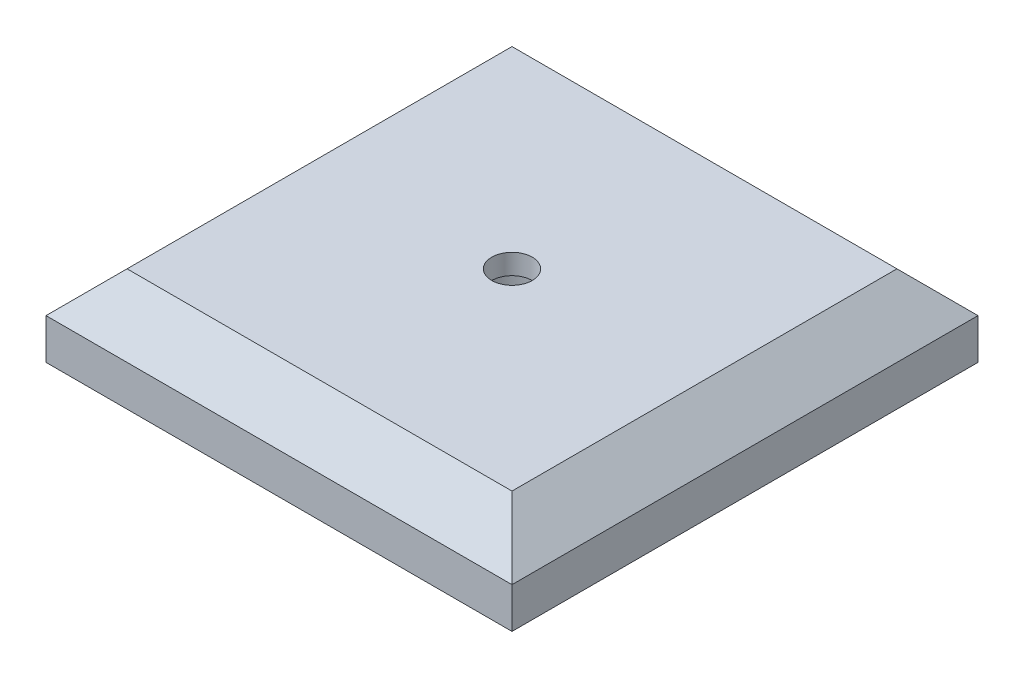
from build123d import *

# Parameters (mm, degrees)
SKETCH1_W           = 28.75
SKETCH1_H           = 28.75
BOSS_EXTRUDE4_DEPTH = 2.5
SKETCH5_W           = 28.75
SKETCH5_H           = 28.75
BOSS_EXTRUDE5_DEPTH = 2.5
BOSS_EXTRUDE5_TAPER = 45
SKETCH6_R           = 1.25
CUT_EXTRUDE5_DEPTH  = 1.25
SKETCH10_R          = 2.5
CUT_EXTRUDE6_DEPTH  = 3.75


with BuildPart() as part:
    # Sketch1 → Boss-Extrude4 (new body)
    with BuildSketch(Plane(origin=(0, 0, 0), x_dir=(1, 0, 0), z_dir=(0, 1, 0))):
        Rectangle(SKETCH1_W, SKETCH1_H)
    extrude(amount=BOSS_EXTRUDE4_DEPTH)

    # Sketch5 → Boss-Extrude5 (add)
    with BuildSketch(Plane(origin=(0, 2.5, 0), x_dir=(1, 0, 0), z_dir=(0, 1, 0))):
        Rectangle(SKETCH5_W, SKETCH5_H)
    extrude(amount=BOSS_EXTRUDE5_DEPTH, taper=BOSS_EXTRUDE5_TAPER)

    # Sketch6 → Cut-Extrude5 (cut)
    with BuildSketch(Plane(origin=(0, 5, 0), x_dir=(1, 0, 0), z_dir=(0, 1, 0))):
        Circle(SKETCH6_R)
    extrude(amount=-CUT_EXTRUDE5_DEPTH, mode=Mode.SUBTRACT)

    # Sketch10 → Cut-Extrude6 (cut)
    with BuildSketch(Plane.XZ):
        Circle(SKETCH10_R)
    extrude(amount=-CUT_EXTRUDE6_DEPTH, mode=Mode.SUBTRACT)


solid = part.part
